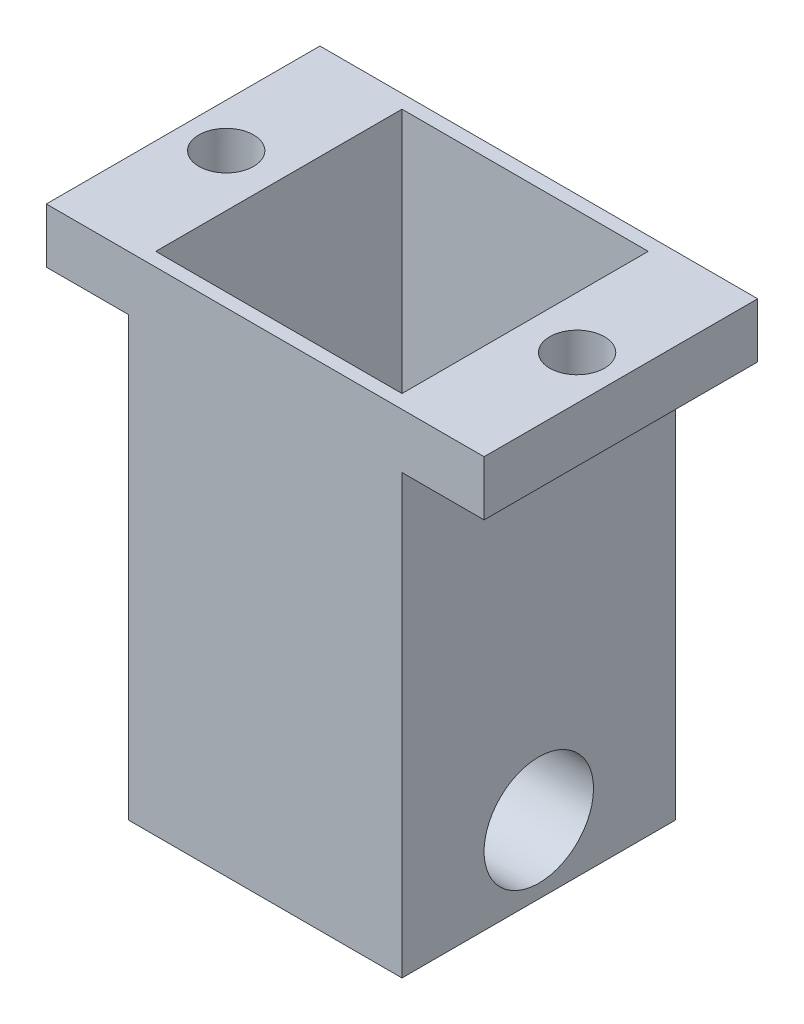
from build123d import *

# Parameters (mm, degrees)
SKETCH1_W                      = 63.5
SKETCH1_H                      = 63.5
BOSS_EXTRUDE1_DEPTH            = 31.75
SKETCH2_W                      = 63.5
SKETCH2_H                      = 63.5
SKETCH2_W_2                    = 57.15
SKETCH2_H_2                    = 57.15
BOSS_EXTRUDE2_DEPTH            = 82.55
SKETCH3_W                      = 63.5
SKETCH3_H                      = 12.7
BOSS_EXTRUDE3_DEPTH            = 19.05
F_1_1_DIAMETER_HOLE2_D         = 25.4
F_1_1_DIAMETER_HOLE2_DEPTH     = 63.5
F_1_2_0_5_DIAMETER_HOLE1_D     = 12.7
F_1_2_0_5_DIAMETER_HOLE1_DEPTH = 12.7


with BuildPart() as part:
    # Sketch1 → Boss-Extrude1 (new body)
    with BuildSketch(Plane(origin=(0, 0, 0), x_dir=(1, 0, 0), z_dir=(0, 1, 0))):
        with Locations((31.75, 31.75)):
            Rectangle(SKETCH1_W, SKETCH1_H)
    extrude(amount=BOSS_EXTRUDE1_DEPTH)

    # Sketch2 → Boss-Extrude2 (add)
    with BuildSketch(Plane(origin=(0, 31.75, 0), x_dir=(1, 0, 0), z_dir=(0, 1, 0))):
        with Locations((31.75, 31.75)):
            Rectangle(SKETCH2_W, SKETCH2_H)
        with Locations((31.75, 31.75)):
            Rectangle(SKETCH2_W_2, SKETCH2_H_2, mode=Mode.SUBTRACT)
    extrude(amount=BOSS_EXTRUDE2_DEPTH)

    # Sketch3 → Boss-Extrude3 (add)
    with BuildSketch(Plane(origin=(63.5, 0, 0), x_dir=(0, 0, -1), z_dir=(1, 0, 0))):
        with Locations((31.75, 107.95)):
            Rectangle(SKETCH3_W, SKETCH3_H)
    boss_extrude3 = extrude(amount=BOSS_EXTRUDE3_DEPTH)

    # Mirror2: Boss-Extrude3 across plane
    add(boss_extrude3.mirror(Plane(origin=(31.75, 0, 0), x_dir=(0, 0, 1), z_dir=(1, 0, 0))))

    # 1 (1) Diameter Hole2
    with Locations(Plane(origin=(63.5, 0, 0), x_dir=(0, 0, -1), z_dir=(1, 0, 0))):
        with Locations((31.75, 15.875)):
            Hole(F_1_1_DIAMETER_HOLE2_D / 2, depth=F_1_1_DIAMETER_HOLE2_DEPTH)

    # 1/2 (0.5) Diameter Hole1
    with Locations(Plane(origin=(0, 114.3, 0), x_dir=(1, 0, 0), z_dir=(0, 1, 0))):
        with Locations((72.39, 31.75), (-8.89, 31.593283178)):
            Hole(F_1_2_0_5_DIAMETER_HOLE1_D / 2, depth=F_1_2_0_5_DIAMETER_HOLE1_DEPTH)


solid = part.part
